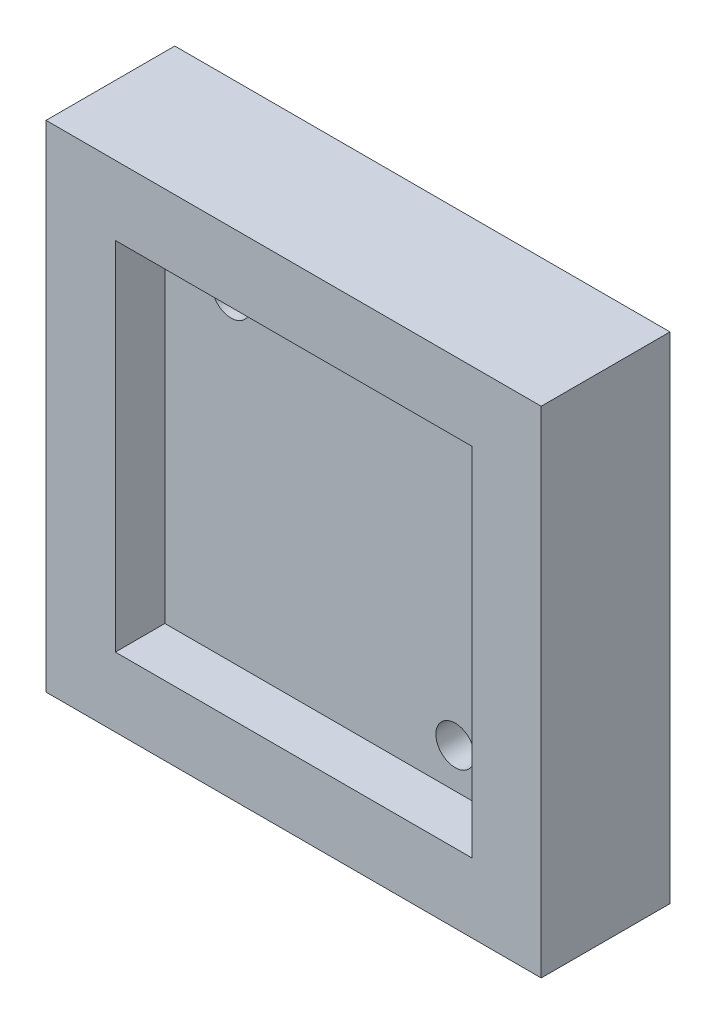
from build123d import *

# Parameters (mm, degrees)
BOSS_EXTRU_1_DEPTH      = 6.5
BOSS_EXTRU_1_DEPTH_BACK = 6.5
ESQUISSE1_W             = 50
ESQUISSE1_H             = 50
ESQUISSE2_W             = 36
ESQUISSE2_H             = 36
ENL_V_MAT_EXTRU_1_DEPTH = 5
ESQUISSE3_W             = 36
ESQUISSE3_H             = 36
ENL_V_MAT_EXTRU_2_DEPTH = 5
D_GAGEMENT_M3_51_D      = 3.9


with BuildPart() as part:
    # Esquisse1 → Boss.-Extru.1 (new, two sides: drawn at the far end of the back side and taken through both)
    with BuildSketch(Plane.XY.offset(-BOSS_EXTRU_1_DEPTH_BACK)):
        Rectangle(ESQUISSE1_W, ESQUISSE1_H)
    extrude(amount=BOSS_EXTRU_1_DEPTH + BOSS_EXTRU_1_DEPTH_BACK)

    # Esquisse2 → Enlèv. mat.-Extru.1 (cut)
    with BuildSketch(Plane.XY.offset(6.5)):
        Rectangle(ESQUISSE2_W, ESQUISSE2_H)
    extrude(amount=-ENL_V_MAT_EXTRU_1_DEPTH, mode=Mode.SUBTRACT)

    # Esquisse3 → Enlèv. mat.-Extru.2 (cut)
    with BuildSketch(Plane(origin=(0, 0, -6.5), x_dir=(-1, 0, 0), z_dir=(0, 0, -1))):
        Rectangle(ESQUISSE3_W, ESQUISSE3_H)
    extrude(amount=-ENL_V_MAT_EXTRU_2_DEPTH, mode=Mode.SUBTRACT)

    # Dégagement M3.51 (through all)
    with Locations(Plane.XY.offset(1.5)):
        with Locations((-11.313708499, 14), (11.313708499, -14)):
            Hole(D_GAGEMENT_M3_51_D / 2)


solid = part.part
